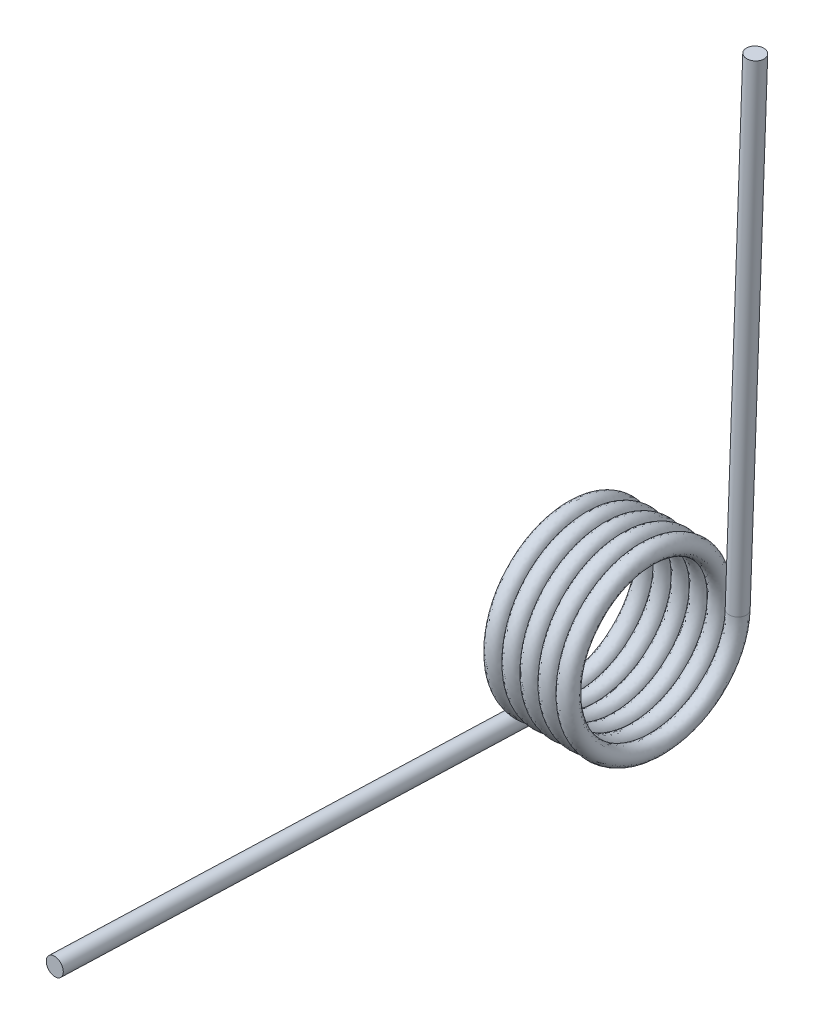
from build123d import *

# Parameters (mm, degrees)
SWEEP1_PITCH        = 1.1684
SWEEP1_HEIGHT       = 6.1341
SWEEP1_RADIUS       = 5.1816
SKETCH4_R           = 0.5715
SKETCH5_R           = 0.5715
BOSS_EXTRUDE1_DEPTH = 31.75
SKETCH6_R           = 0.5715
BOSS_EXTRUDE2_DEPTH = 31.75


with BuildPart() as part:
    # Sweep1: sweep along a helix
    with BuildLine() as sweep1_path:
        Helix(SWEEP1_PITCH, SWEEP1_HEIGHT, SWEEP1_RADIUS, center=(0, 0, 0), direction=(-1, 0, 0))
    # Sketch4 → Sweep1 (sweep)
    with BuildSketch(Plane(origin=(0, 0, 7.0993), x_dir=(-0.999356651, 0.035864791, 0), z_dir=(-0.035864791, -0.999356651, 0))):
        with Locations((0, 12.2809)):
            Circle(SKETCH4_R)
    sweep(path=sweep1_path.line, is_frenet=True)

    # Sketch5 → Boss-Extrude1 (add)
    with BuildSketch(Plane(origin=(-0.00789019, 0, 0.219856678), x_dir=(0.999356651, 0, 0.035864791), z_dir=(-0.035864791, 0, 0.999356651))):
        with Locations((-6.130153636, -5.1816)):
            Circle(SKETCH5_R)
    extrude(amount=BOSS_EXTRUDE1_DEPTH)

    # Sketch6 → Boss-Extrude2 (add)
    with BuildSketch(Plane(origin=(0, 0, 0), x_dir=(0.999356651, -0.035864791, 0), z_dir=(0.035864791, 0.999356651, 0))):
        with Locations((0, 5.1816)):
            Circle(SKETCH6_R)
    extrude(amount=BOSS_EXTRUDE2_DEPTH)


solid = part.part
